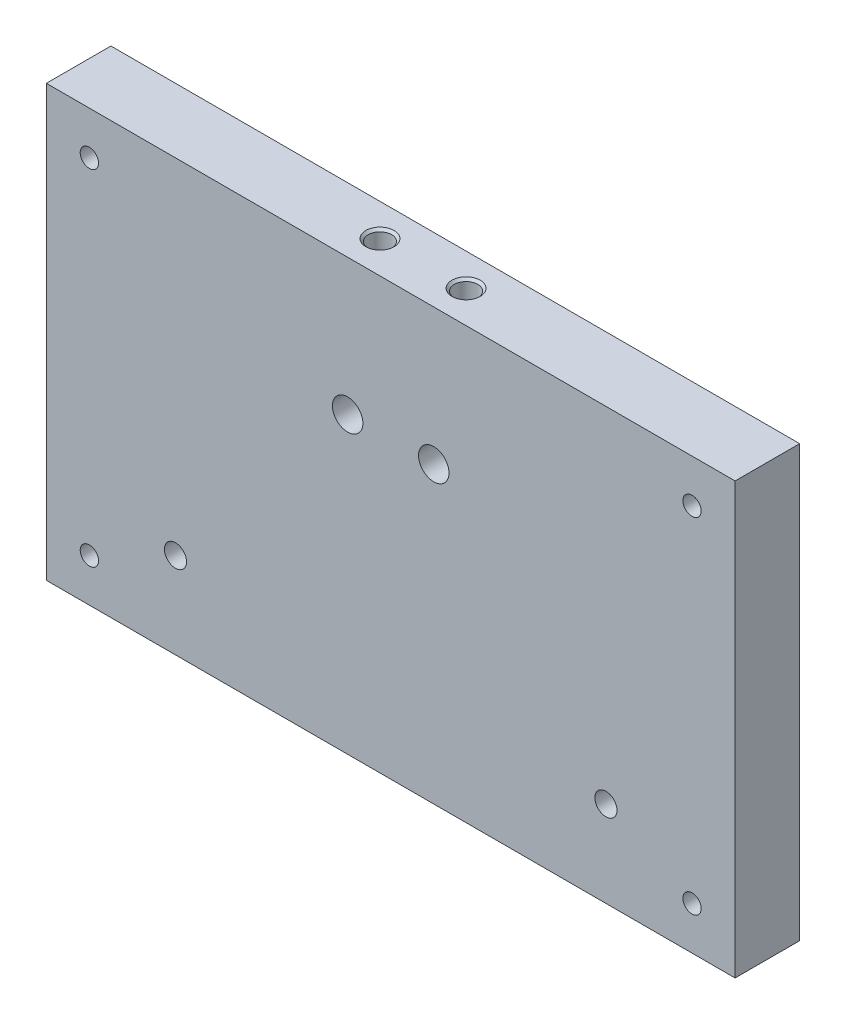
from build123d import *

# Parameters (mm, degrees)
SKETCH1_W                       = 101.6
SKETCH1_H                       = 63.5
BOSS_EXTRUDE1_DEPTH             = 9.525
F_8_32_TAPPED_HOLE1_D           = 3.4544
F_8_32_TAPPED_HOLE1_DEPTH       = 19.05
F_8_32_TAPPED_HOLE1_CSINK_D     = 4.1656
F_8_32_TAPPED_HOLE1_CSINK_ANGLE = 90
F_8_32_TAPPED_HOLE1_TIP         = 1.037806461
F_8_CLEARANCE_HOLE2_D           = 4.4958
F_8_CLEARANCE_HOLE2_DEPTH       = 25.4
F_8_CLEARANCE_HOLE2_TIP         = 1.350674586
F_6_32_TAPPED_HOLE1_D           = 2.7051
F_4_CLEARANCE_HOLE1_D           = 3.2639
F_4_CLEARANCE_HOLE1_DEPTH       = 9.525


with BuildPart() as part:
    # Sketch1 → Boss-Extrude1 (new body)
    with BuildSketch(Plane.XY):
        with Locations((-50.8, 31.75)):
            Rectangle(SKETCH1_W, SKETCH1_H)
    extrude(amount=BOSS_EXTRUDE1_DEPTH)

    # #8-32 Tapped Hole1
    with Locations(Plane(origin=(0, 63.5, 0), x_dir=(1, 0, 0), z_dir=(0, 1, 0))):
        with Locations((-44.45, -4.7625), (-57.15, -4.7625)):
            CounterSinkHole(F_8_32_TAPPED_HOLE1_D / 2, F_8_32_TAPPED_HOLE1_CSINK_D / 2, depth=F_8_32_TAPPED_HOLE1_DEPTH, counter_sink_angle=F_8_32_TAPPED_HOLE1_CSINK_ANGLE)
            with Locations((0, 0, -(F_8_32_TAPPED_HOLE1_DEPTH + F_8_32_TAPPED_HOLE1_TIP / 2))):  # 118° drill point
                Cone(0, F_8_32_TAPPED_HOLE1_D / 2, F_8_32_TAPPED_HOLE1_TIP, mode=Mode.SUBTRACT)

    # #8 Clearance Hole2
    with Locations(Plane.XY.offset(9.525)):
        with Locations((-44.45, 43.412193539), (-57.15, 43.412193539)):
            Hole(F_8_CLEARANCE_HOLE2_D / 2, depth=F_8_CLEARANCE_HOLE2_DEPTH)
            with Locations((0, 0, -(F_8_CLEARANCE_HOLE2_DEPTH + F_8_CLEARANCE_HOLE2_TIP / 2))):  # 118° drill point
                Cone(0, F_8_CLEARANCE_HOLE2_D / 2, F_8_CLEARANCE_HOLE2_TIP, mode=Mode.SUBTRACT)

    # #6-32 Tapped Hole1 (through all)
    with Locations(Plane.XY.offset(9.525)):
        with Locations((-95.25, 6.35), (-95.25, 57.15), (-6.35, 6.35), (-6.35, 57.15)):
            Hole(F_6_32_TAPPED_HOLE1_D / 2)

    # #4 Clearance Hole1
    with Locations(Plane.XY.offset(9.525)):
        with Locations((-82.55, 12.7), (-19.05, 12.7)):
            Hole(F_4_CLEARANCE_HOLE1_D / 2, depth=F_4_CLEARANCE_HOLE1_DEPTH)


solid = part.part
